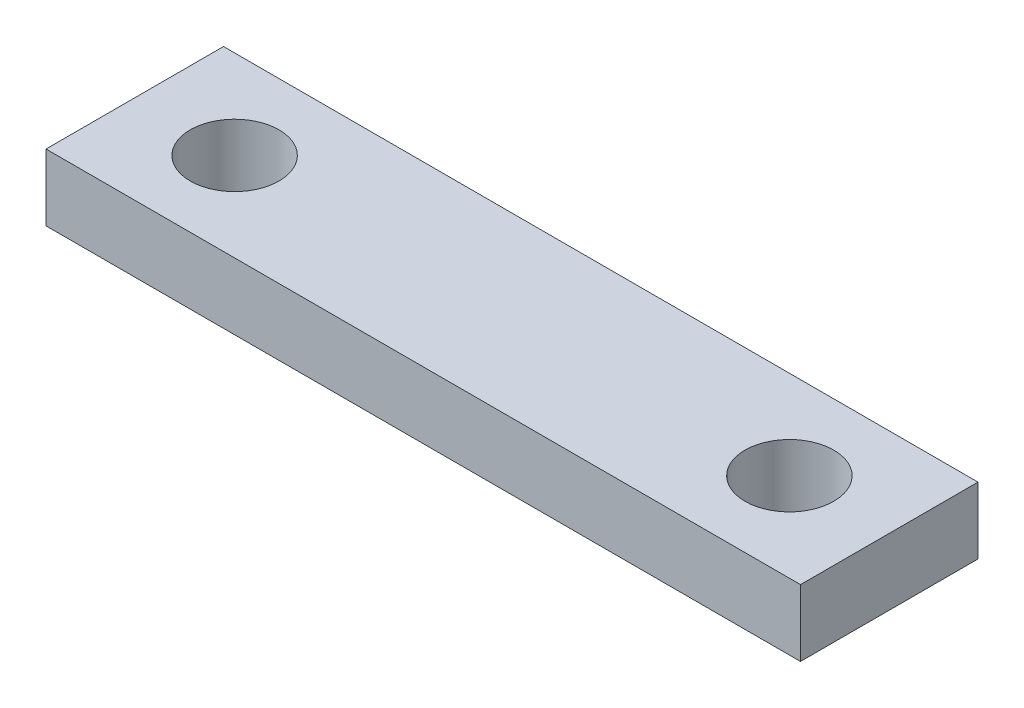
from build123d import *

# Parameters (mm, degrees)
SKETCH1_W           = 34
SKETCH1_H           = 8
SKETCH1_R           = 2
BOSS_EXTRUDE1_DEPTH = 3


with BuildPart() as part:
    # Sketch1 → Boss-Extrude1 (new body)
    with BuildSketch(Plane(origin=(0, 0, 0), x_dir=(1, 0, 0), z_dir=(0, 1, 0))):
        Rectangle(SKETCH1_W, SKETCH1_H)
        with Locations((-12.5, 0)):
            Circle(SKETCH1_R, mode=Mode.SUBTRACT)
        with Locations((12.5, 0)):
            Circle(SKETCH1_R, mode=Mode.SUBTRACT)
    extrude(amount=BOSS_EXTRUDE1_DEPTH)


solid = part.part
